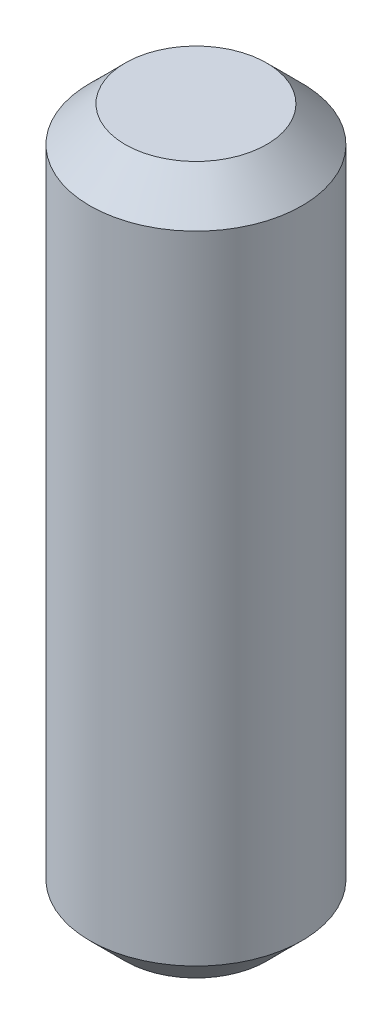
from build123d import *

# Parameters (mm, degrees)
SKETCH_1_R      = 1.5
EXTRUDE_1_DEPTH = 5
CHAMFER_1_SIZE  = 0.5


with BuildPart() as part:
    # 草图1 → 凸台-拉伸1 (new body, symmetric)
    with BuildSketch(Plane(origin=(0, 0, 0), x_dir=(1, 0, 0), z_dir=(0, 1, 0))):
        Circle(SKETCH_1_R)
    extrude(amount=EXTRUDE_1_DEPTH, both=True)

    # 倒角1
    chamfer_1_edges = [part.edges().sort_by_distance(p)[0] for p in [
        (-1.5, -5, 0),
        (-1.5, 5, 0),
    ]]
    chamfer(chamfer_1_edges, length=CHAMFER_1_SIZE)


solid = part.part
